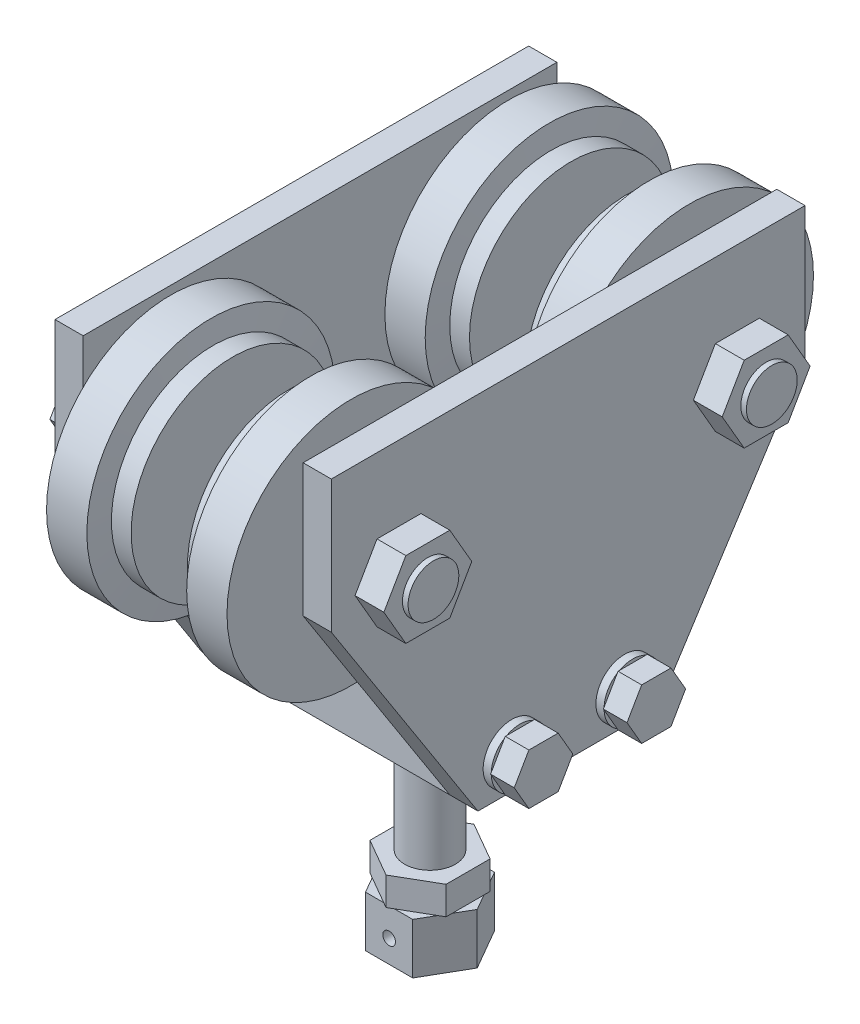
from build123d import *

# Parameters (mm, degrees)
YOKE_CROSS_SECTION_W           = 101.6
YOKE_CROSS_SECTION_H           = 38.1
YOKE_DEPTH                     = 61.9125
SIDEPLATE_DEPTH                = 15.875
WHEEL_PIN_NUT_DEPTH            = 16.2306
WHEEL_PIN_PROJECTION_PROFILE_R = 14.2875
WHEEL_PIN_PROJECTION_DEPTH     = 3.175
LOCKNUTS_PROFILE_R             = 16.129
LOCKNUTS_DEPTH                 = 4.572
SCREWS_DEPTH                   = 13.3096
PROFILE_R                      = 22.225
KING_BOLT_HEAD_DEPTH           = 25.4
DIA_R                          = 14.2875
KING_BOLT_DEPTH                = 83.052101
KING_BOLT_JAM_NUT_DEPTH        = 15.875
KING_BOLT_NUT_DEPTH            = 28.575
SKETCH5_R                      = 14.2875
EXTENDED_KING_BOLT_DEPTH       = 6.35
CHAMFER1_SIZE                  = 2.38125
COTTER_PIN_HOLE_REACH          = 190.119
SKETCH7_R                      = 3.571875


with BuildPart() as part:
    # YOKE CROSS SECTION → YOKE (new body)
    with BuildSketch(Plane(origin=(0, 0, 0), x_dir=(0, 0, -1), z_dir=(1, 0, 0))):
        with Locations((0, 19.05)):
            Rectangle(YOKE_CROSS_SECTION_W, YOKE_CROSS_SECTION_H)
    extrude(amount=YOKE_DEPTH)

    # SIDEPLATE PROFILE → SIDEPLATE (add)
    with BuildSketch(Plane(origin=(61.9125, 0, 0), x_dir=(0, 0, -1), z_dir=(1, 0, 0))):
        Polygon((0, 0), (50.8, 0), (133.35, 128.517771554), (133.35, 203.2), (-133.35, 203.2), (-133.35, 128.517771554), (-50.8, 0), align=None)
    extrude(amount=SIDEPLATE_DEPTH)

    # WHEEL PIN NUT PROFILE → WHEEL PIN NUT (add)
    with BuildSketch(Plane(origin=(77.7875, 0, 0), x_dir=(0, 0, -1), z_dir=(1, 0, 0))):
        Polygon((-70.503324087, 139.7), (-82.876662043, 161.13125), (-107.623337957, 161.13125), (-119.996675913, 139.7), (-107.623337957, 118.26875), (-82.876662043, 118.26875), align=None)
    wheel_pin_nut = extrude(amount=WHEEL_PIN_NUT_DEPTH)

    # WHEEL PIN PROJECTION PROFILE → WHEEL PIN PROJECTION (add)
    with BuildSketch(Plane(origin=(94.0181, 0, 0), x_dir=(0, 0, -1), z_dir=(1, 0, 0))):
        with Locations((-95.25, 139.7)):
            Circle(WHEEL_PIN_PROJECTION_PROFILE_R)
    wheel_pin_projection = extrude(amount=WHEEL_PIN_PROJECTION_DEPTH)

    # LOCKNUTS PROFILE → LOCKNUTS (add)
    with BuildSketch(Plane(origin=(77.7875, 0, 0), x_dir=(0, 0, -1), z_dir=(1, 0, 0))):
        with Locations(Location((-31.75, 19.05, 0), (0, 0, 180))):  # turned: the seam where the file's is
            Circle(LOCKNUTS_PROFILE_R)
    locknuts = extrude(amount=LOCKNUTS_DEPTH)

    # SCREWS PROFILE → SCREWS (add)
    with BuildSketch(Plane(origin=(82.3595, 0, 0), x_dir=(0, 0, -1), z_dir=(1, 0, 0))):
        Polygon((-15.252216058, 19.05), (-23.501108029, 33.3375), (-39.998891971, 33.3375), (-48.247783942, 19.05), (-39.998891971, 4.7625), (-23.501108029, 4.7625), align=None)
    screws = extrude(amount=SCREWS_DEPTH)

    # PROFILE → KING BOLT HEAD (add)
    with BuildSketch(Plane(origin=(0, 38.1, 0), x_dir=(-1, 0, 0), z_dir=(0, 1, 0))):
        with Locations(Location((0, 0, 0), (0, 0, 90))):  # turned: the seam where the file's is
            Circle(PROFILE_R)
    extrude(amount=KING_BOLT_HEAD_DEPTH)

    # Mirror1: WHEEL PIN NUT, WHEEL PIN PROJECTION across plane
    add(wheel_pin_nut.mirror(Plane.XY))
    add(wheel_pin_projection.mirror(Plane.XY))

    # Mirror YOKE SCREWS: LOCKNUTS, SCREWS across plane
    add(locknuts.mirror(Plane.XY))
    add(screws.mirror(Plane.XY))

    # Mirror SIDE 1: part across plane


with BuildPart() as part_1:
    add(part.part)
    add(part.part.mirror(Plane(origin=(0, 0, 0), x_dir=(0, 0, 1), z_dir=(1, 0, 0))))

    # DIA. → KING BOLT (add)
    with BuildSketch(Plane.XZ):
        with Locations(Location((0, 0, 0), (0, 0, 90))):  # turned: the seam where the file's is
            Circle(DIA_R)
    extrude(amount=KING_BOLT_DEPTH)

    # KING BOLT JAN NUT PROFILE → KING BOLT JAM NUT (add)
    with BuildSketch(Plane.XZ.offset(83.052100888)):
        Polygon((0, -24.754008262), (21.4376, -12.377004131), (21.4376, 12.377004131), (0, 24.754008262), (-21.4376, 12.377004131), (-21.4376, -12.377004131), align=None)
    extrude(amount=KING_BOLT_JAM_NUT_DEPTH)

    # KING BOLT NUT PROFILE → KING BOLT NUT (add)
    with BuildSketch(Plane.XZ.offset(98.927100888)):
        Polygon((26.579763018, 0), (13.289881509, 23.01875), (-13.289881509, 23.01875), (-26.579763018, 0), (-13.289881509, -23.01875), (13.289881509, -23.01875), align=None)
    extrude(amount=KING_BOLT_NUT_DEPTH)

    # Sketch5 → EXTENDED KING BOLT (add)
    with BuildSketch(Plane.XZ.offset(127.502100888)):
        with Locations(Location((0, 0, 0), (0, 0, 90))):  # turned: the seam where the file's is
            Circle(SKETCH5_R)
    extrude(amount=EXTENDED_KING_BOLT_DEPTH)

    # Chamfer1
    chamfer1_edges = [part_1.edges().sort_by_distance(p)[0] for p in [
        (0, -133.852100888, -14.2875),
    ]]
    chamfer(chamfer1_edges, length=CHAMFER1_SIZE)

    # Sketch6 → WHEEL (revolve)
    with BuildSketch(Plane.XY.offset(95.25), mode=Mode.PRIVATE) as wheel_sk:
        Polygon((15.875, 196.85), (15.875, 139.7), (61.9125, 139.7), (61.9125, 158.75), (50.8, 158.75), (50.8, 209.55), (28.1051, 209.55), (26.9875, 196.85), align=None)
    wheel = revolve(wheel_sk.sketch.rotate(Axis((97.1931, 139.7, 95.25), (-1, 0, 0)), 90), axis=Axis((97.1931, 139.7, 95.25), (-1, 0, 0)))  # turned: the seam where the file's is

    # Mirror2: WHEEL across plane
    add(wheel.mirror(Plane.XY))

    # Mirror3: WHEEL across plane
    add(wheel.mirror(Plane(origin=(0, 0, 0), x_dir=(0, 0, 1), z_dir=(1, 0, 0))))

    # Mirror3 copy 1 sketch → Mirror3 copy 1 (revolve)
    with BuildSketch(Plane(origin=(0, 0, -95.25), x_dir=(-1, 0, 0), z_dir=(0, 0, -1))):
        Polygon((15.875, 196.85), (15.875, 139.7), (61.9125, 139.7), (61.9125, 158.75), (50.8, 158.75), (50.8, 209.55), (28.1051, 209.55), (26.9875, 196.85), align=None)
    revolve(axis=Axis((-97.1931, 139.7, -95.25), (1, 0, 0)))

    # Sketch7 → COTTER PIN HOLE (cut, up to next)
    with BuildSketch(Plane.XY.offset(23.01875), mode=Mode.PRIVATE) as cotter_pin_hole_sk1:
        with Locations((0, -114.802100888)):
            Circle(SKETCH7_R)
    cotter_pin_hole_tool1 = extrude(cotter_pin_hole_sk1.sketch, amount=-COTTER_PIN_HOLE_REACH, mode=Mode.PRIVATE) & part_1.part
    add(cotter_pin_hole_tool1.solids().sort_by_distance((0, -114.802101, 23.01875))[0], mode=Mode.SUBTRACT)


solid = part_1.part
